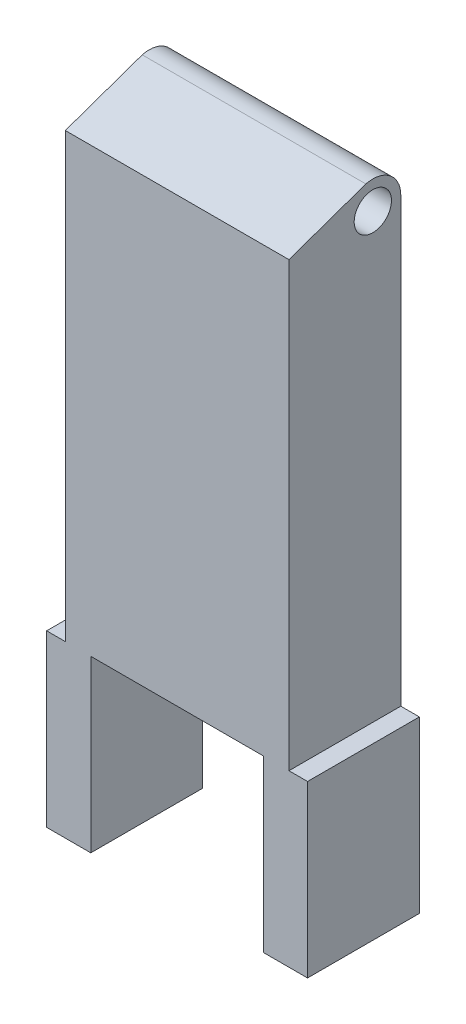
from build123d import *

# Parameters (mm, degrees)
EXTRUDE_1_DEPTH      = 12
EXTRUDE_4_DEPTH      = 24
SKETCH_16_R          = 2
CUT_EXTRUDE_11_DEPTH = 27.005399728


with BuildPart() as part:
    # 스케치1 → 보스-돌출1 (new body)
    with BuildSketch(Plane.XY):
        Polygon((-11.994395335, 44.774969809), (-11.994395335, -2.725030191), (-13.999795062, -2.725030191), (-13.999795062, -20.993190191), (-9.261084312, -20.993190191), (-9.261084312, -2.725030191), (9.261494188, -2.727088258), (9.261494188, -20.993190191), (14.000204938, -20.993190191), (14.000204938, -2.727088258), (12.005604665, -2.727088258), (12.005604665, 44.774969809), align=None)
    extrude(amount=EXTRUDE_1_DEPTH)

    # 스케치15 → 보스-돌출4 (add)
    with BuildSketch(Plane(origin=(12.005604665, 0, 0), x_dir=(0, 0, -1), z_dir=(1, 0, 0))):
        with BuildLine():
            Line((-12, 44.774969809), (-3.746682541, 47.680561863))
            ThreePointArc((-3.746682541, 47.680561863), (-1.161528845, 47.145628749), (0, 44.774969809))
            Line((0, 44.774969809), (-12, 44.774969809))
        make_face()
    extrude(amount=-EXTRUDE_4_DEPTH)

    # 스케치16 → 컷-돌출11 (cut, through all)
    with BuildSketch(Plane(origin=(12.005604665, 0, 0), x_dir=(0, 0, -1), z_dir=(1, 0, 0))):
        with Locations((-3, 44.774969809)):
            Circle(SKETCH_16_R)
    extrude(amount=-CUT_EXTRUDE_11_DEPTH, mode=Mode.SUBTRACT)


solid = part.part
